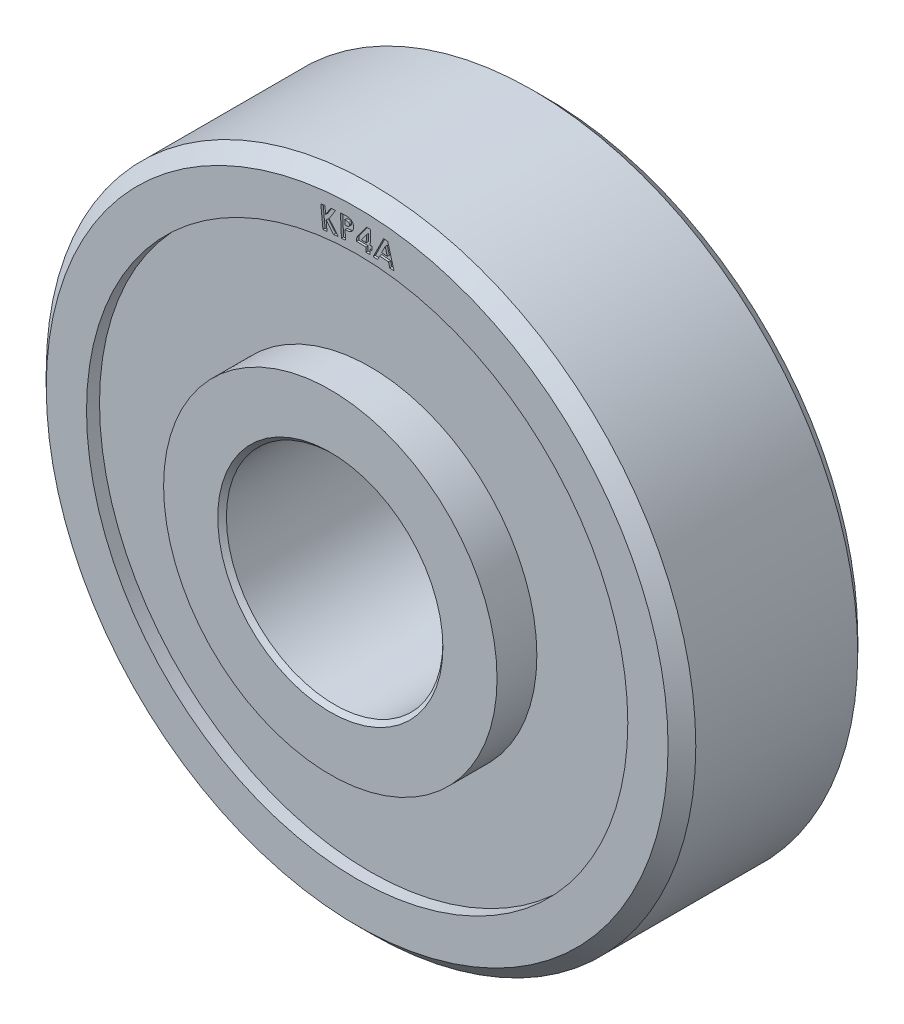
from build123d import *

# Parameters (mm, degrees)
CUT_EXTRUDE1_DEPTH = 0.0635


with BuildPart() as part:
    # Sketch1 → Revolve1 (revolve)
    with BuildSketch(Plane(origin=(0, 0, 0), x_dir=(0, 0, -1), z_dir=(1, 0, 0))):
        Polygon((-3.5687, 3.302), (-3.5687, 4.8895), (-2.4003, 4.8895), (-2.4003, 7.9375), (-2.7813, 7.9375), (-2.7813, 9.1186), (-2.3749, 9.525), (2.3749, 9.525), (2.7813, 9.1186), (2.7813, 7.9375), (2.4003, 7.9375), (2.4003, 4.8895), (3.5687, 4.8895), (3.5687, 3.302), (3.4417, 3.175), (-3.4417, 3.175), align=None)
    revolve(axis=Axis((0, 0, 0), (0, 0, -1)))

    # Sketch2 → Cut-Extrude1 (cut)
    with BuildSketch(Plane.XY.offset(2.7813)):
        Polygon((-1.065389716, 8.689257304), (-0.944927977, 8.700960028), (-0.923812192, 8.485731663), (-0.775238474, 8.71762369), (-0.6318801, 8.731743282), (-0.823194203, 8.43116135), (-0.549325012, 8.108064395), (-0.690520926, 8.094199211), (-0.910837432, 8.352931182), (-0.883615878, 8.075245886), (-1.004077616, 8.063543161), align=None)
        with BuildLine():
            Line((-0.489550779, 8.745205417), (-0.362092846, 8.750802372))
            add(Edge.make_bspline(
                [(-0.362092846, 8.750802372), (-0.353783496, 8.751094885), (-0.337719442, 8.751660387), (-0.314512555, 8.751859917), (-0.293097259, 8.751130036), (-0.273426615, 8.750177126), (-0.25557832, 8.748042626), (-0.239408839, 8.745617462), (-0.225080822, 8.742341467), (-0.212298345, 8.738378299), (-0.200823557, 8.733485202), (-0.189914069, 8.728251603), (-0.179779185, 8.721890908), (-0.169997559, 8.715093426), (-0.160982847, 8.707235014), (-0.152469707, 8.698745309), (-0.144499674, 8.68948952), (-0.137163657, 8.679508609), (-0.130573946, 8.668808831), (-0.124668367, 8.657561061), (-0.119619418, 8.645720508), (-0.115250492, 8.633375845), (-0.111835881, 8.620431699), (-0.109185181, 8.606920008), (-0.107217999, 8.592822714), (-0.106684397, 8.583196649), (-0.106413759, 8.578314391)],
                knots=[0, 0, 0, 0, 2.4944e-05, 4.8222e-05, 6.9602e-05, 8.9225e-05, 0.000107275, 0.000123504, 0.000138253, 0.000151328, 0.000163588, 0.000175649, 0.000187582, 0.000199441, 0.000211348, 0.000223401, 0.000235488, 0.000247954, 0.000260521, 0.000273152, 0.00028603, 0.000299104, 0.000312403, 0.000326149, 0.000340397, 0.00035506, 0.00035506, 0.00035506, 0.00035506], degree=3))
            add(Edge.make_bspline(
                [(-0.106413759, 8.578314391), (-0.106301145, 8.57292907), (-0.106079291, 8.562319767), (-0.106956067, 8.546709533), (-0.108985222, 8.531734852), (-0.112150836, 8.517427274), (-0.116516958, 8.503788963), (-0.121841952, 8.490732201), (-0.128357362, 8.47833375), (-0.136015471, 8.466683627), (-0.144501712, 8.455688158), (-0.154040626, 8.445647342), (-0.164159304, 8.436201955), (-0.175157805, 8.427603876), (-0.187090246, 8.420035009), (-0.19964346, 8.412982658), (-0.213097771, 8.406836734), (-0.222481909, 8.403469396), (-0.227257109, 8.401755898)],
                knots=[0, 0, 0, 0, 1.6155e-05, 3.1827e-05, 4.6848e-05, 6.1445e-05, 7.5727e-05, 8.9758e-05, 0.000103699, 0.00011767, 0.000131538, 0.000145307, 0.000159169, 0.000173037, 0.000187115, 0.000201521, 0.000216207, 0.000231422, 0.000231422, 0.000231422, 0.000231422], degree=3))
            add(Edge.make_bspline(
                [(-0.227257109, 8.401755898), (-0.230428994, 8.40083463), (-0.237276115, 8.398845897), (-0.248567522, 8.396319688), (-0.261647847, 8.394081399), (-0.276541992, 8.392071054), (-0.293213358, 8.390303809), (-0.3117114, 8.388833395), (-0.331976204, 8.387396251), (-0.346105902, 8.38671699), (-0.353443006, 8.386364271)],
                knots=[0, 0, 0, 0, 9.907e-06, 2.1387e-05, 3.4687e-05, 4.9708e-05, 6.6467e-05, 8.4975e-05, 0.000105375, 0.000127411, 0.000127411, 0.000127411, 0.000127411], degree=3))
            Line((-0.353443006, 8.386364271), (-0.341740282, 8.118855257))
            Line((-0.341740282, 8.118855257), (-0.461947614, 8.113639912))
            Line((-0.461947614, 8.113639912), (-0.489550779, 8.745205417))
        make_face()
        with BuildLine():
            Line((-0.358531147, 8.503518718), (-0.32037009, 8.505172364))
            add(Edge.make_bspline(
                [(-0.32037009, 8.505172364), (-0.313456644, 8.505592798), (-0.300711051, 8.506367909), (-0.283338162, 8.508066241), (-0.269442305, 8.510743628), (-0.258483675, 8.513806757), (-0.249827521, 8.518175494), (-0.242563252, 8.523364305), (-0.236339925, 8.529632522), (-0.231078239, 8.53675751), (-0.227040183, 8.54486288), (-0.224012592, 8.553649742), (-0.222695566, 8.563264025), (-0.222683841, 8.569831817), (-0.222677782, 8.57322625)],
                knots=[0, 0, 0, 0, 2.0781e-05, 3.8312e-05, 5.2308e-05, 6.3212e-05, 7.2314e-05, 8.1246e-05, 8.9881e-05, 9.8709e-05, 0.000107697, 0.000116949, 0.000126466, 0.000136645, 0.000136645, 0.000136645, 0.000136645], degree=3))
            add(Edge.make_bspline(
                [(-0.222677782, 8.57322625), (-0.222917637, 8.576158471), (-0.22338335, 8.581851802), (-0.224998846, 8.590031341), (-0.227597902, 8.59754684), (-0.23099774, 8.604406251), (-0.235304004, 8.610636746), (-0.240375218, 8.61626779), (-0.246452189, 8.62116902), (-0.251005053, 8.62378647), (-0.253333831, 8.625125289)],
                knots=[0, 0, 0, 0, 8.822e-06, 1.7129e-05, 2.4933e-05, 3.2613e-05, 4.0023e-05, 4.7587e-05, 5.5275e-05, 6.3325e-05, 6.3325e-05, 6.3325e-05, 6.3325e-05], degree=3))
            add(Edge.make_bspline(
                [(-0.253333831, 8.625125289), (-0.255266589, 8.626057529), (-0.259374974, 8.628039155), (-0.266333987, 8.630303419), (-0.274399852, 8.632008988), (-0.283527412, 8.633423979), (-0.293729577, 8.634232301), (-0.304971839, 8.634778726), (-0.31732103, 8.634719634), (-0.325925391, 8.634433422), (-0.330419168, 8.634283942)],
                knots=[0, 0, 0, 0, 6.432e-06, 1.3673e-05, 2.1882e-05, 3.1147e-05, 4.1362e-05, 5.2568e-05, 6.4906e-05, 7.8395e-05, 7.8395e-05, 7.8395e-05, 7.8395e-05], degree=3))
            Line((-0.330419168, 8.634283942), (-0.364255306, 8.6327575))
            Line((-0.364255306, 8.6327575), (-0.358531147, 8.503518718))
        make_face(mode=Mode.SUBTRACT)
        Polygon((0.274619381, 8.766223521), (0.394826713, 8.762407416), (0.381979157, 8.355737744), (0.438203115, 8.353956895), (0.434641417, 8.242781013), (0.378417458, 8.244561863), (0.374346945, 8.11494147), (0.256810888, 8.118630372), (0.260881401, 8.248250765), (-0.01476864, 8.257027808), (-0.011206941, 8.36820369), align=None)
        Polygon((0.264443099, 8.359426646), (0.271057683, 8.571093313), (0.120194301, 8.364005973), align=None, mode=Mode.SUBTRACT)
        Polygon((0.774863847, 8.722125534), (0.896852028, 8.710550013), (1.080152309, 8.056087873), (0.955238446, 8.067790598), (0.91822222, 8.202626335), (0.660635081, 8.226922208), (0.596778911, 8.101753939), (0.471737845, 8.113456663), align=None)
        Polygon((0.820911523, 8.548747128), (0.716350225, 8.339878939), (0.884131675, 8.323978498), align=None, mode=Mode.SUBTRACT)
    extrude(amount=-CUT_EXTRUDE1_DEPTH, mode=Mode.SUBTRACT)


solid = part.part
